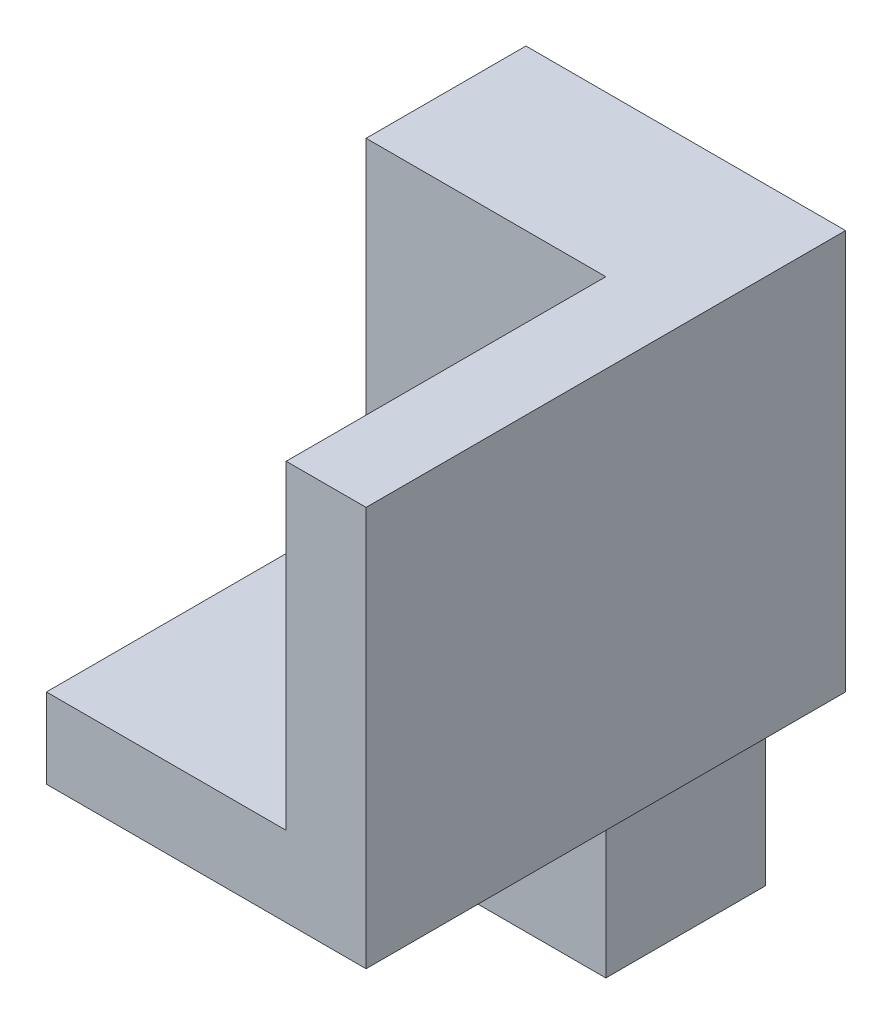
from build123d import *

# Parameters (mm, degrees)
BOSS_EXTRUDE1_DEPTH = 10
BOSS_EXTRUDE5_DEPTH = 5
SKETCH3_W           = 30
SKETCH3_H           = 25
BOSS_EXTRUDE6_DEPTH = 5


with BuildPart() as part:
    # Sketch1 → Boss-Extrude1 (new body)
    with BuildSketch(Plane(origin=(0, 0, 0), x_dir=(0, 0, -1), z_dir=(1, 0, 0))):
        Polygon((0, 0), (-10, 0), (-10, -20), (-30, -20), (-30, -25), (-10, -25), (-10, -38), (0, -38), align=None)
    extrude(amount=BOSS_EXTRUDE1_DEPTH)

    # Sketch2 → Boss-Extrude5 (add)
    with BuildSketch(Plane.ZY):
        Polygon((0, 0), (10, 0), (10, -20), (30, -20), (30, -25), (0, -25), align=None)
    extrude(amount=BOSS_EXTRUDE5_DEPTH)

    # Sketch3 → Boss-Extrude6 (add)
    with BuildSketch(Plane(origin=(10, 0, 0), x_dir=(0, 0, -1), z_dir=(1, 0, 0))):
        with Locations((-15, -12.5)):
            Rectangle(SKETCH3_W, SKETCH3_H)
    extrude(amount=BOSS_EXTRUDE6_DEPTH)


solid = part.part
